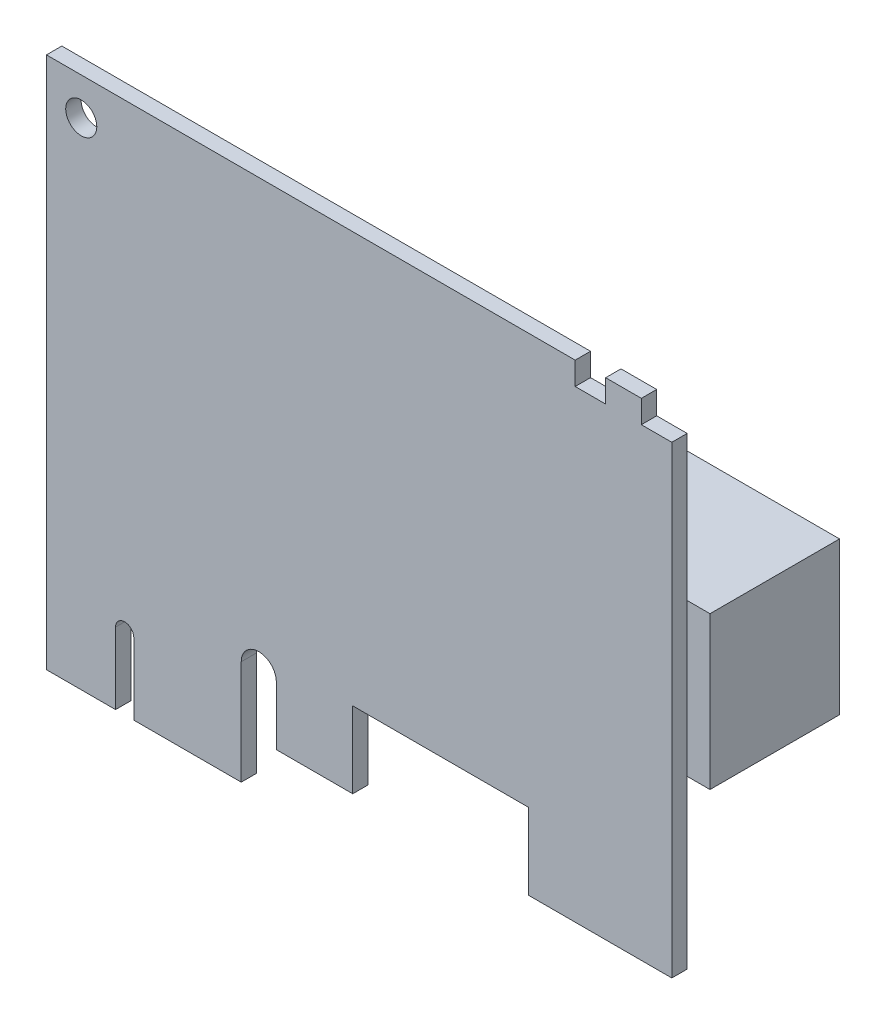
from build123d import *

# Parameters (mm, degrees)
SKETCH2_R           = 1.61925
BOSS_EXTRUDE1_DEPTH = 1.6
SKETCH3_W           = 22.225
SKETCH3_H           = 15.875
BOSS_EXTRUDE2_DEPTH = 13.5


with BuildPart() as part:
    # Sketch2 → Boss-Extrude1 (new body)
    with BuildSketch(Plane.XY):
        with BuildLine():
            Line((0, 0), (7.2, 0))
            Line((7.2, 0), (7.2, 7.45))
            ThreePointArc((7.2, 7.45), (8.15, 8.4), (9.1, 7.45))
            Line((9.1, 7.45), (9.1, 0))
            Line((9.1, 0), (20.3, 0))
            Line((20.3, 0), (20.3, 10.8712))
            ThreePointArc((20.3, 10.8712), (22.1288, 12.7), (23.9576, 10.8712))
            Line((23.9576, 10.8712), (23.9576, 4.7625))
            Line((23.9576, 4.7625), (31.9205, 4.7625))
            Line((31.9205, 4.7625), (31.9205, 12.7))
            Line((31.9205, 12.7), (50.2593, 12.7))
            Line((50.2593, 12.7), (50.2593, 4.7625))
            Line((50.2593, 4.7625), (65.1764, 4.7625))
            Line((65.1764, 4.7625), (65.1764, 53.11875))
            Line((65.1764, 53.11875), (62.0014, 53.11875))
            Line((62.0014, 53.11875), (62.0014, 55.5))
            Line((62.0014, 55.5), (58.2814, 55.5))
            Line((58.2814, 55.5), (58.2814, 53.11875))
            Line((58.2814, 53.11875), (55.1064, 53.11875))
            Line((55.1064, 53.11875), (55.1064, 55.5))
            Line((55.1064, 55.5), (0, 55.5))
            Line((0, 55.5), (0, 0))
        make_face()
        with Locations((3.625, 51.625)):
            Circle(SKETCH2_R, mode=Mode.SUBTRACT)
    extrude(amount=BOSS_EXTRUDE1_DEPTH)

    # Sketch3 → Boss-Extrude2 (add)
    with BuildSketch(Plane(origin=(0, 0, 0), x_dir=(-1, 0, 0), z_dir=(0, 0, -1))):
        with Locations((-56.44515, 30.1)):
            Rectangle(SKETCH3_W, SKETCH3_H)
    extrude(amount=BOSS_EXTRUDE2_DEPTH)


solid = part.part
